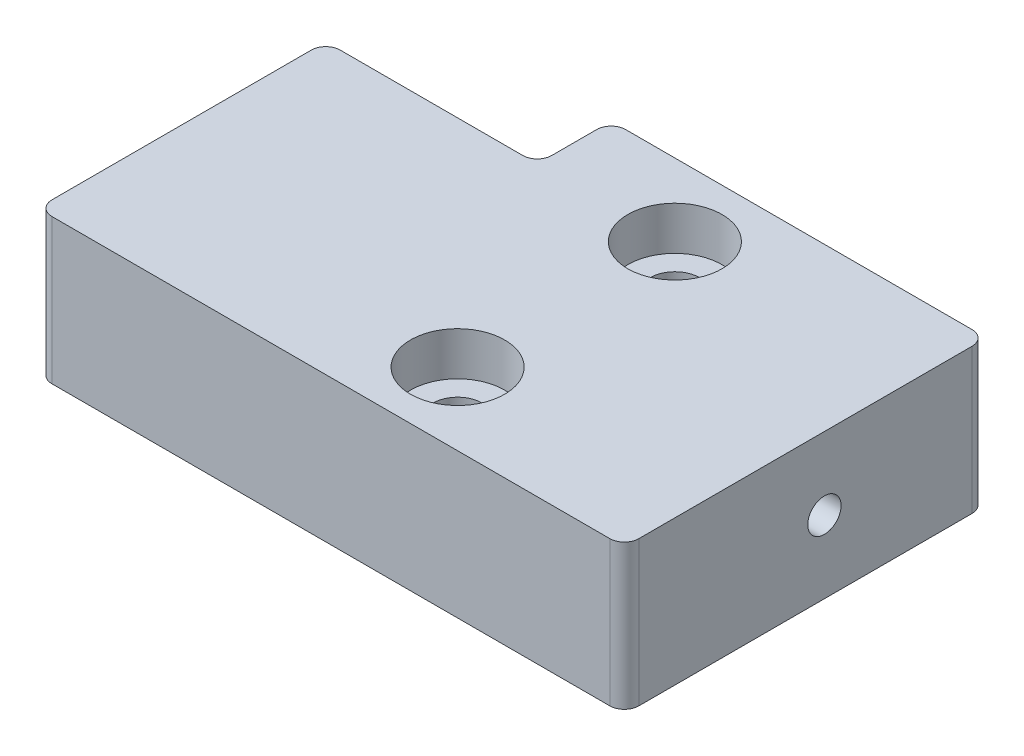
from build123d import *

# Parameters (mm, degrees)
BOSS_EXTRUDE1_DEPTH            = 10
FILLET1_R                      = 1
CBORE_FOR_M3_SHCS1_D           = 3.4
CBORE_FOR_M3_SHCS1_DEPTH       = 10
CBORE_FOR_M3_SHCS1_CBORE_D     = 6.5
CBORE_FOR_M3_SHCS1_CBORE_DEPTH = 3
SKETCH5_R                      = 1.15
CUT_EXTRUDE1_DEPTH             = 2.5


with BuildPart() as part:
    # Sketch1 → Boss-Extrude1 (new body)
    with BuildSketch(Plane(origin=(0, 0, 0), x_dir=(1, 0, 0), z_dir=(0, 1, 0))):
        Polygon((0, 0), (40.51, 0), (40.51, 25), (14.6, 25), (14.6, 19.9), (0, 19.9), align=None)
    extrude(amount=BOSS_EXTRUDE1_DEPTH)

    # Fillet1
    fillet1_edges = [part.edges().sort_by_distance(p)[0] for p in [
        (0, 5, -19.9),
        (14.6, 5, -19.9),
        (14.6, 5, -25),
        (40.51, 5, -25),
        (40.51, 5, 0),
        (0, 5, 0),
    ]]
    fillet(fillet1_edges, radius=FILLET1_R)

    # CBORE for M3 SHCS1
    with Locations(Plane(origin=(0, 10, 0), x_dir=(1, 0, 0), z_dir=(0, 1, 0))):
        with Locations((24, 20), (24, 5)):
            CounterBoreHole(CBORE_FOR_M3_SHCS1_D / 2, CBORE_FOR_M3_SHCS1_CBORE_D / 2, CBORE_FOR_M3_SHCS1_CBORE_DEPTH, depth=CBORE_FOR_M3_SHCS1_DEPTH)

    # Sketch5 → Cut-Extrude1 (cut, symmetric)
    with BuildSketch(Plane(origin=(40.51, 0, 0), x_dir=(0, 0, -1), z_dir=(1, 0, 0))):
        with Locations((13.81, 5)):
            Circle(SKETCH5_R)
    extrude(amount=CUT_EXTRUDE1_DEPTH, both=True, mode=Mode.SUBTRACT)


solid = part.part
